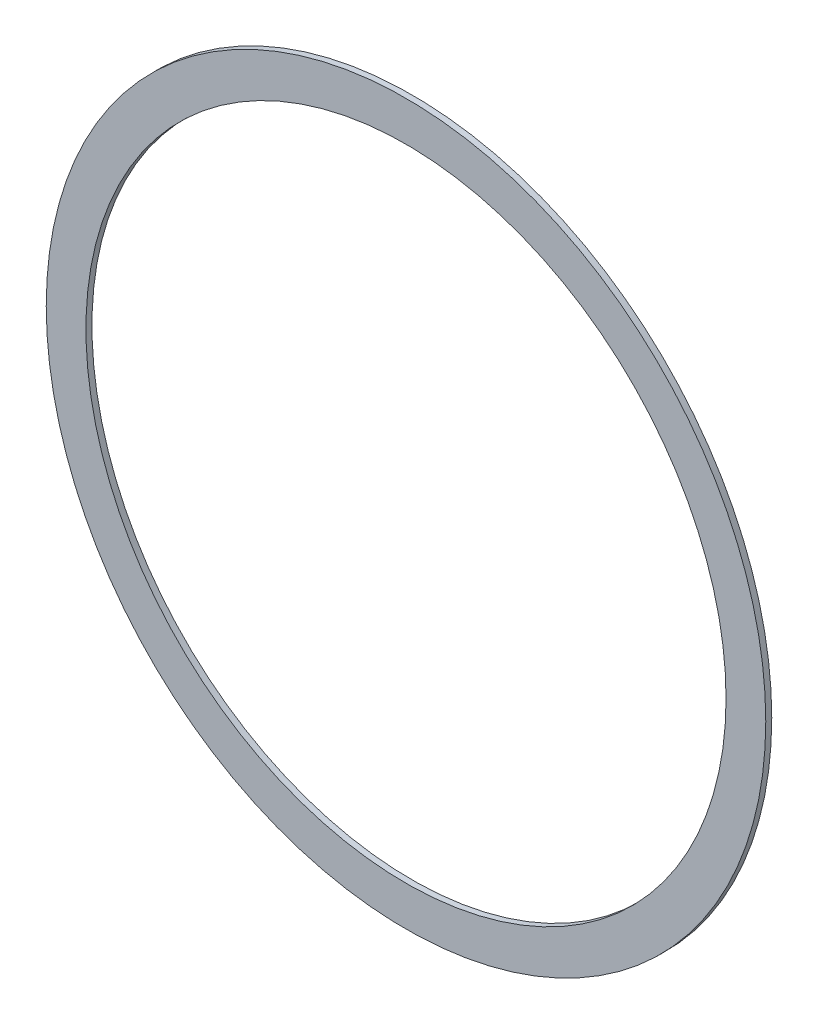
from build123d import *

# Parameters (mm, degrees)
SKETCH2_R           = 190.5
SKETCH2_R_2         = 169.4688
BOSS_EXTRUDE2_DEPTH = 3.175


with BuildPart() as part:
    # Sketch2 → Boss-Extrude2 (new body)
    with BuildSketch(Plane.XY):
        Circle(SKETCH2_R)
        Circle(SKETCH2_R_2, mode=Mode.SUBTRACT)
    extrude(amount=BOSS_EXTRUDE2_DEPTH)


solid = part.part
